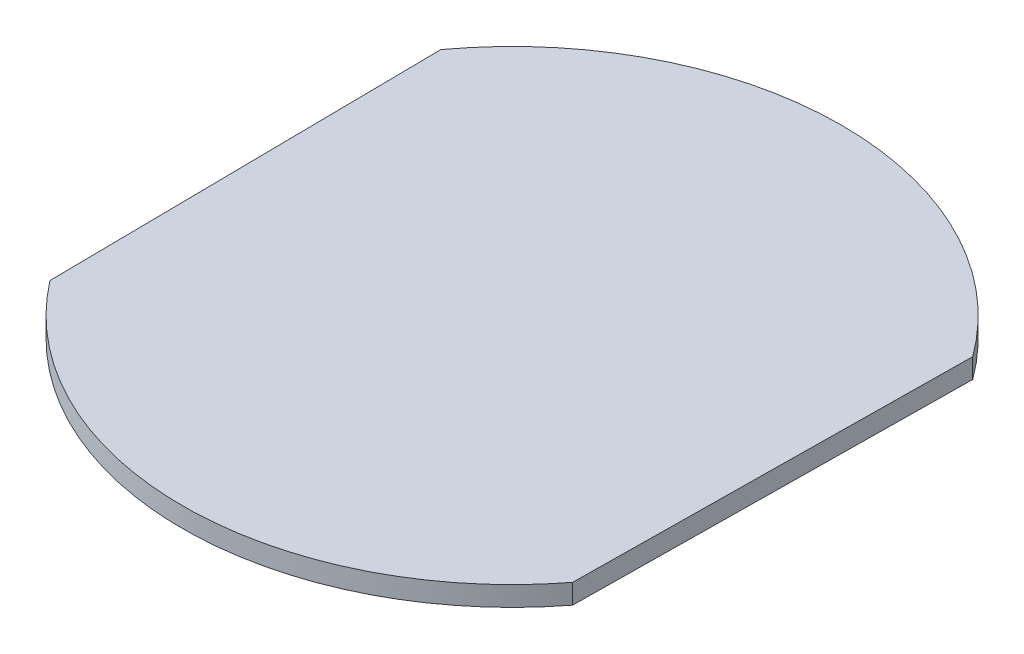
from build123d import *

# Parameters (mm, degrees)
BOSS_EXTRUDE1_DEPTH = 1.5


with BuildPart() as part:
    # Sketch1 → Boss-Extrude1 (new body, symmetric)
    with BuildSketch(Plane(origin=(0, 0, 0), x_dir=(1, 0, 0), z_dir=(0, 1, 0))):
        with BuildLine():
            Line((39.648494152, -30.463041731), (40.346098424, 29.532902701))
            ThreePointArc((40.346098424, 29.532902701), (0, 50), (-40.346098424, 29.532902701))
            Line((-40.346098424, 29.532902701), (-39.648494152, -30.463041731))
            ThreePointArc((-39.648494152, -30.463041731), (0, -50), (39.648494152, -30.463041731))
        make_face()
    extrude(amount=BOSS_EXTRUDE1_DEPTH, both=True)


solid = part.part
